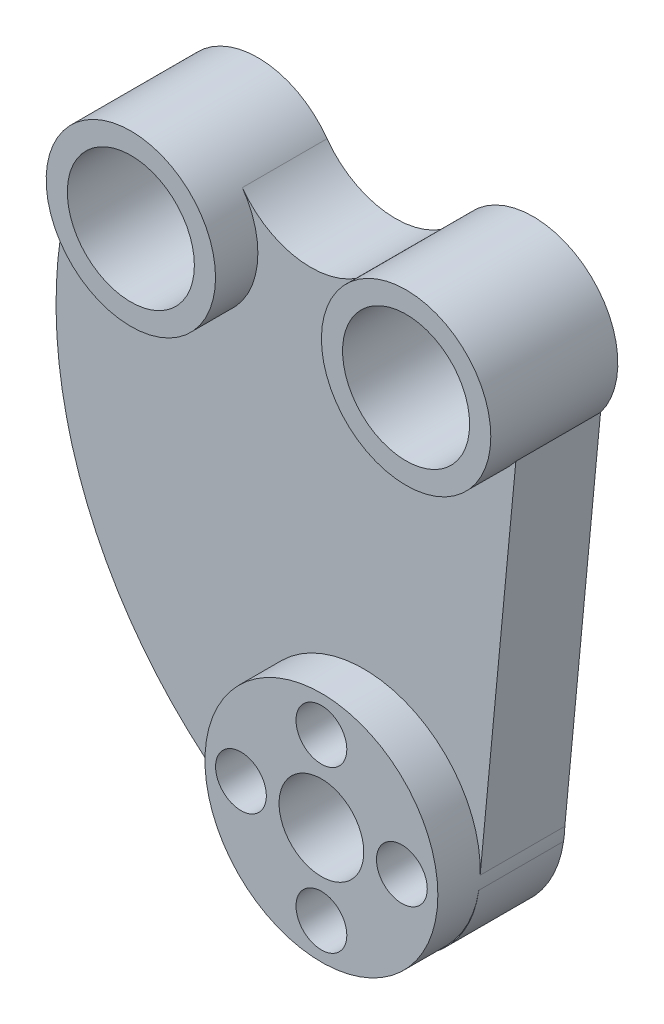
from build123d import *

# Parameters (mm, degrees)
SKETCH1_R               = 27.5
SKETCH1_R_2             = 19
SKETCH1_R_3             = 10
BOSS_EXTRUDE1_DEPTH     = 30
SKETCH2_R               = 20
SKETCH2_R_2             = 15
BOSS_EXTRUDE2_DEPTH     = 30
BOSS_EXTRUDE2_2_DEPTH   = 30
SKETCH5_R               = 6
CUT_EXTRUDE1_DEPTH      = 30
BOSS_EXTRUDE3_DEPTH     = 20
SKETCH7_R               = 15
SKETCH7_R_2             = 6
SKETCH7_R_3             = 10
CUT_EXTRUDE2_DEPTH      = 11
CUT_EXTRUDE2_DEPTH_BACK = 21


with BuildPart() as part:
    # Sketch1 → Boss-Extrude1 (new body)
    with BuildSketch(Plane.XY):
        Circle(SKETCH1_R)
        Circle(SKETCH1_R_2, mode=Mode.SUBTRACT)
        Circle(SKETCH1_R_2)
        Circle(SKETCH1_R_3, mode=Mode.SUBTRACT)
    extrude(amount=BOSS_EXTRUDE1_DEPTH)

    # Sketch5 → Cut-Extrude1 (cut)
    with BuildSketch(Plane.XY):
        with Locations((0, 19)):
            Circle(SKETCH5_R)
        with Locations((-19, 0)):
            Circle(SKETCH5_R)
        with Locations((0, -19)):
            Circle(SKETCH5_R)
        with Locations((19, 0)):
            Circle(SKETCH5_R)
    extrude(amount=CUT_EXTRUDE1_DEPTH, mode=Mode.SUBTRACT)



with BuildPart() as body_2:
    # Sketch2 → Boss-Extrude2 (new body)
    with BuildSketch(Plane.XY):
        with Locations((-45, 100)):
            Circle(SKETCH2_R)
        with Locations((-45, 100)):
            Circle(SKETCH2_R_2, mode=Mode.SUBTRACT)
    extrude(amount=BOSS_EXTRUDE2_DEPTH)


with BuildPart() as body_3:
    # Sketch2 → Boss-Extrude2 2 (new body)
    with BuildSketch(Plane.XY):
        with Locations((20, 100)):
            Circle(SKETCH2_R)
        with Locations((20, 100)):
            Circle(SKETCH2_R_2, mode=Mode.SUBTRACT)
    extrude(amount=BOSS_EXTRUDE2_2_DEPTH)


with BuildPart() as part_1:
    add(part.part)

    add(body_2.part)  # Boss-Extrude3 merges body 2

    add(body_3.part)  # Boss-Extrude3 merges body 3
    # Sketch6 → Boss-Extrude3 (add)
    with BuildSketch(Plane.XY):
        with BuildLine():
            Line((35.914568173, 87.886927728), (27.176428779, -4.206152493))
            ThreePointArc((27.176428779, -4.206152493), (14.094792579, -23.82005481), (-9.394166008, -25.845689099))
            ThreePointArc((-9.394166008, -25.845689099), (-66.335656198, 31.148009393), (-61.323361203, 111.556291751))
            ThreePointArc((-61.323361203, 111.556291751), (-45, 119.870223993), (-28.676638797, 111.556291751))
            ThreePointArc((-28.676638797, 111.556291751), (-12.5, 103.317089225), (3.676638797, 111.556291751))
            ThreePointArc((3.676638797, 111.556291751), (31.685854827, 115.916260455), (35.914568173, 87.886927728))
        make_face()
    extrude(amount=BOSS_EXTRUDE3_DEPTH)

    # Sketch7 → Cut-Extrude2 (cut, two sides)
    with BuildSketch(Plane.XY.offset(20)) as cut_extrude2_sk:
        with Locations((-45, 100)):
            Circle(SKETCH7_R)
        with Locations((20, 100)):
            Circle(SKETCH7_R)
        with Locations((0, 19)):
            Circle(SKETCH7_R_2)
        with Locations((-19, 0)):
            Circle(SKETCH7_R_2)
        with Locations((0, -19)):
            Circle(SKETCH7_R_2)
        with Locations((19, 0)):
            Circle(SKETCH7_R_2)
        Circle(SKETCH7_R_3)
    extrude(amount=CUT_EXTRUDE2_DEPTH, mode=Mode.SUBTRACT)
    extrude(cut_extrude2_sk.sketch, amount=-CUT_EXTRUDE2_DEPTH_BACK, mode=Mode.SUBTRACT)


solid = part_1.part
